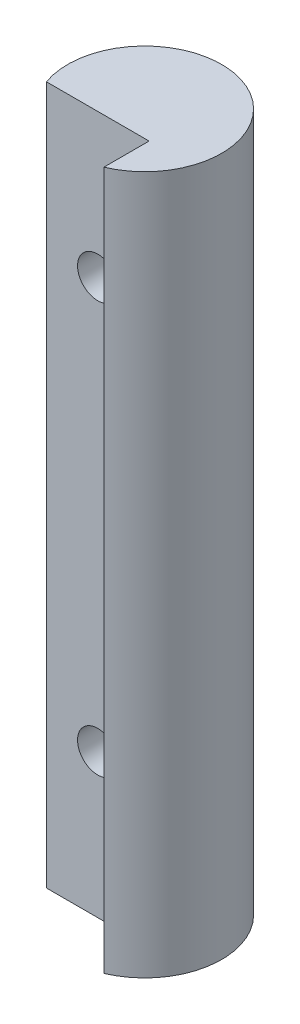
from build123d import *

# Parameters (mm, degrees)
PROFILE_SKETCH_R       = 4.7625
BOSS_EXTRUDE1_DEPTH    = 43.18
PLATE_RELIEF_CUT_REACH = 45.18
PLATE_RELIEF_SKETCH_W  = 6.35
PLATE_RELIEF_SKETCH_H  = 3.175
M3X0_5_TAPPED_HOLE1_D  = 2.5


with BuildPart() as part:
    # Profile Sketch → Boss-Extrude1 (new body)
    with BuildSketch(Plane(origin=(0, 0, 0), x_dir=(1, 0, 0), z_dir=(0, 1, 0))):
        Circle(PROFILE_SKETCH_R)
    extrude(amount=BOSS_EXTRUDE1_DEPTH)

    # Plate Relief Sketch → Plate Relief Cut (cut, up to next)
    with BuildSketch(Plane.XZ, mode=Mode.PRIVATE) as plate_relief_cut_sk1:
        with Locations((-1.315128061, 3.175)):
            Rectangle(PLATE_RELIEF_SKETCH_W, PLATE_RELIEF_SKETCH_H)
    plate_relief_cut_tool1 = extrude(plate_relief_cut_sk1.sketch, amount=-PLATE_RELIEF_CUT_REACH, mode=Mode.PRIVATE) & part.part
    add(plate_relief_cut_tool1.solids().sort_by_distance((-1.315128, 0, 3.175))[0], mode=Mode.SUBTRACT)

    # M3x0.5 Tapped Hole1 (through all)
    with Locations(Plane(origin=(-1.315128061, 34.29, 1.5875), x_dir=(1, 0, 0), z_dir=(0, 0, 1))):
        with Locations((0, 0), (0, -25.4)):
            Hole(M3X0_5_TAPPED_HOLE1_D / 2)


solid = part.part
